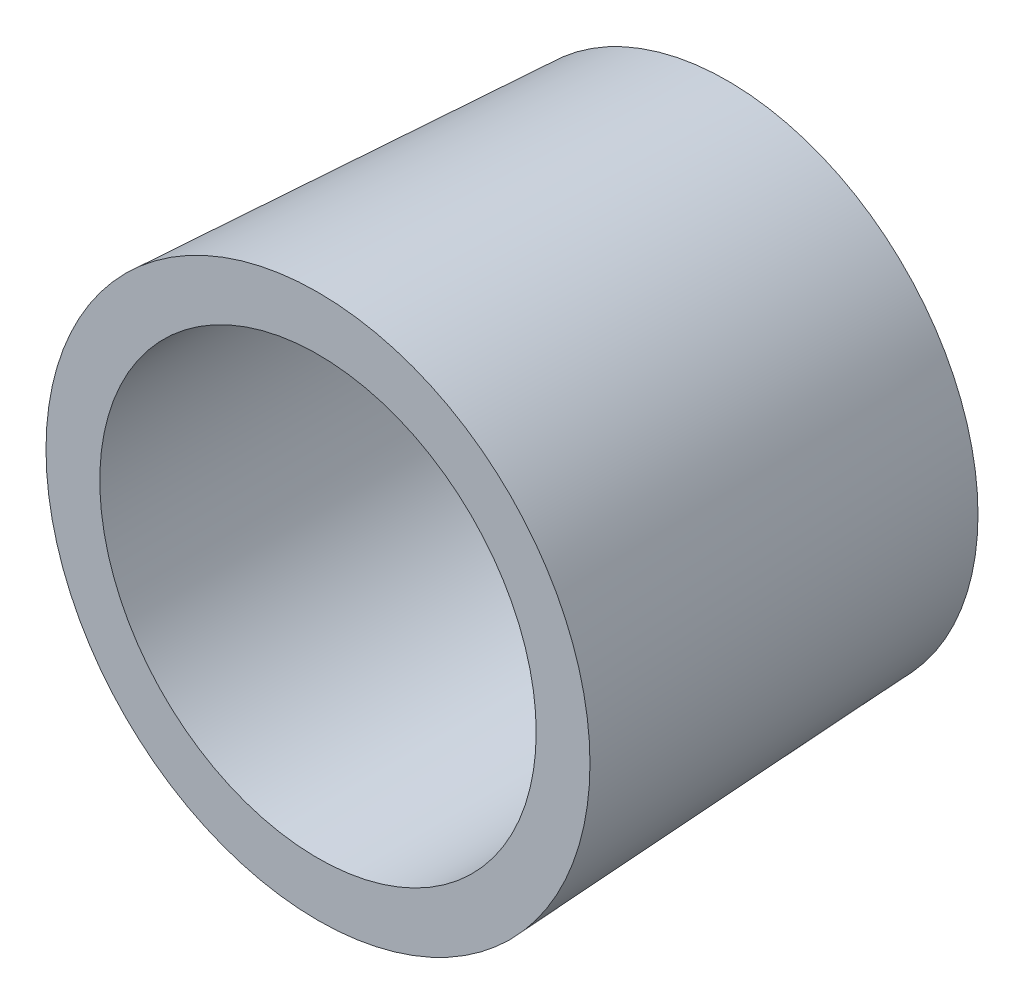
from build123d import *

# Parameters (mm, degrees)
SKETCH1_R           = 23.25
BOSS_EXTRUDE1_DEPTH = 3
BOSS_EXTRUDE2_START = 35
SKETCH1_3_R         = 23.25
SKETCH1_3_R_2       = 20.25
BOSS_EXTRUDE2_DEPTH = 35
SKETCH6_W           = 3
SKETCH6_H           = 3
CUT_EXTRUDE1_DEPTH  = 50.992661477


with BuildPart() as part:
    # Sketch1 → Boss-Extrude1 (new body)
    with BuildSketch(Plane.XY):
        Circle(SKETCH1_R)
    extrude(amount=-BOSS_EXTRUDE1_DEPTH)

    # Sketch1_3 → Boss-Extrude2 (add)
    with BuildSketch(Plane.XY.offset(BOSS_EXTRUDE2_START)):
        Circle(SKETCH1_3_R)
        Circle(SKETCH1_3_R_2, mode=Mode.SUBTRACT)
    extrude(amount=-BOSS_EXTRUDE2_DEPTH)

    # Sketch4 → Revolve2 (revolve)
    with BuildSketch(Plane(origin=(0, 0, 0), x_dir=(1, 0, 0), z_dir=(0, 1, 0))):
        Polygon((23.25, -35), (23.25, 3), (25.241495613, -35), align=None)
    revolve(axis=Axis((0, 0, 0), (0, 0, 1)))

    # Sketch6 → Cut-Extrude1 (cut, through all)
    with BuildSketch(Plane.XY):
        with Locations((5, 0)):
            Rectangle(SKETCH6_W, SKETCH6_H)
        Rectangle(SKETCH6_W, SKETCH6_H)
        with Locations((10, 0)):
            Rectangle(SKETCH6_W, SKETCH6_H)
        with Locations((5, 5)):
            Rectangle(SKETCH6_W, SKETCH6_H)
        with Locations((10, 5)):
            Rectangle(SKETCH6_W, SKETCH6_H)
        with Locations((5, 10)):
            Rectangle(SKETCH6_W, SKETCH6_H)
        with Locations((10, 10)):
            Rectangle(SKETCH6_W, SKETCH6_H)
        with Locations((0, 5)):
            Rectangle(SKETCH6_W, SKETCH6_H)
        with Locations((0, 10)):
            Rectangle(SKETCH6_W, SKETCH6_H)
        with Locations((0, -10)):
            Rectangle(SKETCH6_W, SKETCH6_H)
        with Locations((5, -10)):
            Rectangle(SKETCH6_W, SKETCH6_H)
        with Locations((10, -10)):
            Rectangle(SKETCH6_W, SKETCH6_H)
        with Locations((10, -5)):
            Rectangle(SKETCH6_W, SKETCH6_H)
        with Locations((5, -5)):
            Rectangle(SKETCH6_W, SKETCH6_H)
        with Locations((0, -5)):
            Rectangle(SKETCH6_W, SKETCH6_H)
        with Locations((-10, -10)):
            Rectangle(SKETCH6_W, SKETCH6_H)
        with Locations((-5, -10)):
            Rectangle(SKETCH6_W, SKETCH6_H)
        with Locations((-5, -5)):
            Rectangle(SKETCH6_W, SKETCH6_H)
        with Locations((-10, -5)):
            Rectangle(SKETCH6_W, SKETCH6_H)
        with Locations((-10, 0)):
            Rectangle(SKETCH6_W, SKETCH6_H)
        with Locations((-5, 0)):
            Rectangle(SKETCH6_W, SKETCH6_H)
        with Locations((-5, 5)):
            Rectangle(SKETCH6_W, SKETCH6_H)
        with Locations((-10, 5)):
            Rectangle(SKETCH6_W, SKETCH6_H)
        with Locations((-10, 10)):
            Rectangle(SKETCH6_W, SKETCH6_H)
        with Locations((-5, 10)):
            Rectangle(SKETCH6_W, SKETCH6_H)
    extrude(amount=-CUT_EXTRUDE1_DEPTH, mode=Mode.SUBTRACT)


solid = part.part
